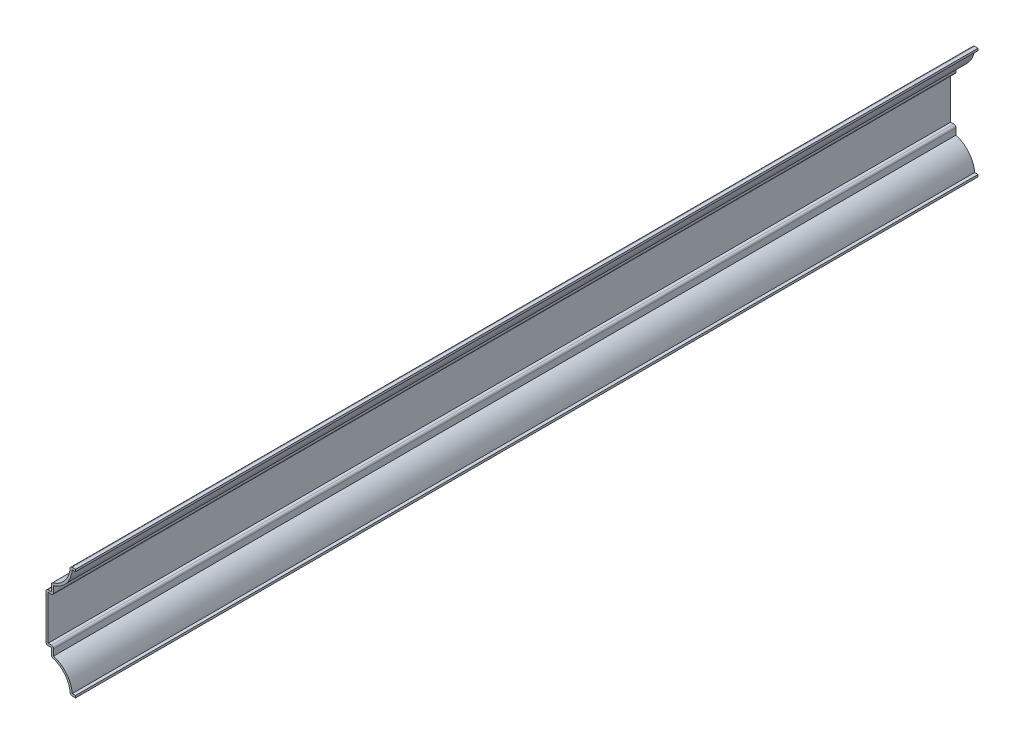
from build123d import *

# Parameters (mm, degrees)
EXTRUDE_THIN1_DEPTH = 533.4
FILLET1_R           = 1.27


with BuildPart() as part:
    # Sketch1 → Extrude-Thin1 (new body)
    with BuildSketch(Plane.XY):
        with BuildLine():
            Line((0, 0), (-3.175, 0))
            ThreePointArc((-3.175, 0), (-6.294965924, 8.894339761), (-14.2875, 13.890625))
            Line((-14.2875, 13.890625), (-14.2875, 18.653125))
            Line((-14.2875, 18.653125), (-17.4625, 18.653125))
            Line((-17.4625, 18.653125), (-17.4625, 47.228125))
            Line((-17.4625, 47.228125), (-14.2875, 47.228125))
            Line((-14.2875, 47.228125), (-14.2875, 51.990625))
            ThreePointArc((-14.2875, 51.990625), (-6.294965924, 56.986910239), (-3.175, 65.88125))
            Line((-3.175, 65.88125), (0, 65.88125))
            Line((0, 65.88125), (0, 64.61125))
            Line((0, 64.61125), (-1.957090043, 64.61125))
            ThreePointArc((-1.957090043, 64.61125), (-5.380817599, 56.097391338), (-13.0175, 51.009289373))
            Line((-13.0175, 51.009289373), (-13.0175, 45.958125))
            Line((-13.0175, 45.958125), (-16.1925, 45.958125))
            Line((-16.1925, 45.958125), (-16.1925, 19.923125))
            Line((-16.1925, 19.923125), (-13.0175, 19.923125))
            Line((-13.0175, 19.923125), (-13.0175, 14.871960627))
            ThreePointArc((-13.0175, 14.871960627), (-5.380817599, 9.783858662), (-1.957090043, 1.27))
            Line((-1.957090043, 1.27), (0, 1.27))
            Line((0, 1.27), (0, 0))
        make_face()
    extrude(amount=-EXTRUDE_THIN1_DEPTH)

    # Fillet1
    fillet1_edges = [part.edges().sort_by_distance(p)[0] for p in [
        (-3.175, 0, -266.7),
        (-14.2875, 13.890625, -266.7),
        (-17.4625, 18.653125, -266.7),
        (-17.4625, 47.228125, -266.7),
        (-14.2875, 51.990625, -266.7),
        (-3.175, 65.88125, -266.7),
        (-13.0175, 45.958125, -266.7),
        (-13.0175, 19.923125, -266.7),
    ]]
    fillet(fillet1_edges, radius=FILLET1_R)


solid = part.part
